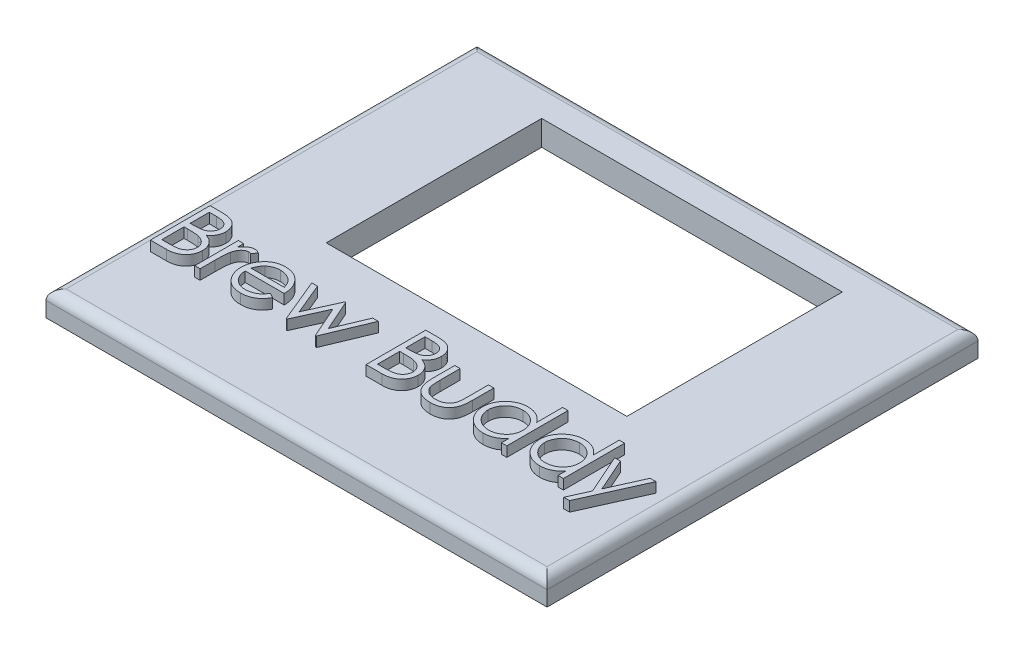
from build123d import *

# Parameters (mm, degrees)
SKETCH1_W           = 100
SKETCH1_H           = 86
BOSS_EXTRUDE1_DEPTH = 5
SKETCH2_W           = 60
SKETCH2_H           = 43
CUT_EXTRUDE1_DEPTH  = 5
BOSS_EXTRUDE2_DEPTH = 2
FILLET1_R           = 2
SKETCH5_R           = 2.65
CUT_EXTRUDE2_DEPTH  = 3


with BuildPart() as part:
    # Sketch1 → Boss-Extrude1 (new body)
    with BuildSketch(Plane(origin=(0, 0, 0), x_dir=(1, 0, 0), z_dir=(0, 1, 0))):
        Rectangle(SKETCH1_W, SKETCH1_H)
    extrude(amount=BOSS_EXTRUDE1_DEPTH)

    # Sketch2 → Cut-Extrude1 (cut)
    with BuildSketch(Plane(origin=(0, 5, 0), x_dir=(1, 0, 0), z_dir=(0, 1, 0))):
        with Locations((0, 14.426515267)):
            Rectangle(SKETCH2_W, SKETCH2_H)
    extrude(amount=-CUT_EXTRUDE1_DEPTH, mode=Mode.SUBTRACT)

    # Sketch4 → Boss-Extrude2 (add)
    with BuildSketch(Plane(origin=(0, 5, 0), x_dir=(1, 0, 0), z_dir=(0, 1, 0))):
        with BuildLine():
            Line((-46.0249044, -14.23647048), (-43.701850013, -14.23647048))
            add(Edge.make_bspline(
                [(-43.701850013, -14.23647048), (-43.588133493, -14.237068345), (-43.367722577, -14.238227156), (-43.047208225, -14.256199236), (-42.747004682, -14.280704578), (-42.467024885, -14.319587304), (-42.20739821, -14.366503974), (-41.96734223, -14.423319973), (-41.747620304, -14.491446222), (-41.485299299, -14.599780446), (-41.186212051, -14.760763724), (-40.862367519, -14.998645718), (-40.58544774, -15.289608829), (-40.346688929, -15.617822148), (-40.156865477, -15.9788733), (-40.019537778, -16.364156791), (-39.932595363, -16.768703073), (-39.923653993, -17.04643567), (-39.919135169, -17.186797252)],
                knots=[0, 0, 0, 0, 1.001505555, 1.941167018, 2.826882275, 3.653841531, 4.429895133, 5.150066043, 5.825578002, 6.45369114, 7.647487171, 8.808567382, 9.977351308, 11.170798116, 12.373658725, 13.556498008, 14.765093433, 16, 16, 16, 16], degree=3))
            add(Edge.make_bspline(
                [(-39.919135169, -17.186797252), (-39.922854064, -17.318284964), (-39.930162043, -17.576670718), (-40.000044108, -17.954589071), (-40.10944781, -18.314332057), (-40.261525488, -18.654586779), (-40.459176029, -18.967665409), (-40.693417274, -19.25609352), (-40.976026754, -19.507659169), (-41.187764918, -19.648298864), (-41.295318312, -19.719737457)],
                knots=[0, 0, 0, 0, 1.044552857, 2.05264487, 3.044412934, 4.028983338, 5.005914585, 5.980388656, 6.974128949, 8, 8, 8, 8], degree=3))
            add(Edge.make_bspline(
                [(-41.295318312, -19.719737457), (-41.160061857, -19.771665712), (-40.901282754, -19.871017328), (-40.545163372, -20.046670112), (-40.238339837, -20.237721577), (-39.978453117, -20.446359388), (-39.756188416, -20.671247396), (-39.562106535, -20.915683098), (-39.396502932, -21.182855122), (-39.254604504, -21.469977863), (-39.143880611, -21.77411951), (-39.060959008, -22.092427239), (-39.013444739, -22.423759655), (-39.006683209, -22.649248311), (-39.003269784, -22.763081808)],
                knots=[0, 0, 0, 0, 1.27268992, 2.434971085, 3.483601985, 4.442670788, 5.356604649, 6.2567628, 7.179492994, 8.113709626, 9.066344395, 10.018646069, 10.999752585, 12, 12, 12, 12], degree=3))
            add(Edge.make_bspline(
                [(-39.003269784, -22.763081808), (-39.006592805, -22.879310185), (-39.013130942, -23.107992774), (-39.061368167, -23.44393658), (-39.143042004, -23.764979925), (-39.255542958, -24.073199341), (-39.402371903, -24.367998549), (-39.581060781, -24.649711527), (-39.79411994, -24.915507777), (-40.032458806, -25.168340816), (-40.302091641, -25.395674628), (-40.592997914, -25.598134309), (-40.908841199, -25.764638324), (-41.244434143, -25.904506219), (-41.603541325, -26.011346778), (-41.984550195, -26.086092766), (-42.38713215, -26.136456329), (-42.663390321, -26.140596999), (-42.805065157, -26.14272048)],
                knots=[0, 0, 0, 0, 0.978564426, 1.925352924, 2.850884081, 3.763762016, 4.682927383, 5.618979971, 6.567305752, 7.547517671, 8.540179244, 9.531824382, 10.526200242, 11.540722885, 12.589160233, 13.674978461, 14.80764778, 16, 16, 16, 16], degree=3))
            Line((-42.805065157, -26.14272048), (-46.0249044, -26.14272048))
            Line((-46.0249044, -26.14272048), (-46.0249044, -14.23647048))
        make_face()
        with BuildLine():
            Line((-44.956394784, -15.457624326), (-44.956394784, -19.273730095))
            Line((-44.956394784, -19.273730095), (-44.238489886, -19.273730095))
            add(Edge.make_bspline(
                [(-44.238489886, -19.273730095), (-44.133548895, -19.272369643), (-43.930781514, -19.269740971), (-43.637139723, -19.262211061), (-43.364571581, -19.241126645), (-43.113547577, -19.220048289), (-42.884463013, -19.185776701), (-42.677825413, -19.144982069), (-42.490391793, -19.101837543), (-42.274243875, -19.028462771), (-42.029067148, -18.920021751), (-41.767697392, -18.751729165), (-41.537279241, -18.551281142), (-41.342706665, -18.31999046), (-41.183464073, -18.065311738), (-41.072859382, -17.791308511), (-40.997859245, -17.504809669), (-40.991084482, -17.308124363), (-40.987644784, -17.208262847)],
                knots=[0, 0, 0, 0, 1.156816544, 2.235205308, 3.236616184, 4.169592532, 5.011045266, 5.787822928, 6.49130361, 7.128639758, 8.301311294, 9.436451833, 10.541879658, 11.654887649, 12.756523258, 13.837046038, 14.901820046, 16, 16, 16, 16], degree=3))
            add(Edge.make_bspline(
                [(-40.987644784, -17.208262847), (-40.989434736, -17.142180535), (-40.992945923, -17.012552864), (-41.021702247, -16.823585865), (-41.070577657, -16.645863814), (-41.133355208, -16.476951171), (-41.221082801, -16.322129609), (-41.324372796, -16.176046059), (-41.449169653, -16.04367537), (-41.591219083, -15.91995413), (-41.754534131, -15.810265156), (-41.939017364, -15.714196132), (-42.14716473, -15.636836882), (-42.375468281, -15.569086399), (-42.627442249, -15.521501221), (-42.900178899, -15.481858894), (-43.195912184, -15.461676977), (-43.400512935, -15.459005341), (-43.506274592, -15.457624326)],
                knots=[0, 0, 0, 0, 0.91205012, 1.789085906, 2.630437955, 3.453916878, 4.269457761, 5.079663411, 5.91843418, 6.774407191, 7.675494373, 8.627863946, 9.638891023, 10.736472738, 11.911756761, 13.175263542, 14.539845004, 16, 16, 16, 16], degree=3))
            Line((-43.506274592, -15.457624326), (-44.956394784, -15.457624326))
        make_face(mode=Mode.SUBTRACT)
        with BuildLine():
            Line((-44.956394784, -20.494883941), (-44.956394784, -24.921566633))
            Line((-44.956394784, -24.921566633), (-43.434722609, -24.921566633))
            add(Edge.make_bspline(
                [(-43.434722609, -24.921566633), (-43.325801084, -24.920261207), (-43.115869204, -24.91774517), (-42.812765913, -24.909531372), (-42.53183589, -24.890847827), (-42.274361071, -24.8614365), (-42.037561228, -24.829533025), (-41.824277077, -24.78663215), (-41.632779696, -24.737479882), (-41.410730488, -24.661503814), (-41.160687304, -24.543473855), (-40.891228944, -24.365512067), (-40.651654041, -24.153501529), (-40.448209365, -23.908127616), (-40.281477681, -23.641321048), (-40.160185463, -23.358478385), (-40.085377281, -23.064273153), (-40.076321151, -22.863681032), (-40.0717794, -22.763081808)],
                knots=[0, 0, 0, 0, 1.160039823, 2.235823828, 3.228722157, 4.157150951, 4.99529583, 5.772374946, 6.472645482, 7.099169577, 8.269452708, 9.405989375, 10.527446681, 11.663510218, 12.788923519, 13.866172445, 14.929861265, 16, 16, 16, 16], degree=3))
            add(Edge.make_bspline(
                [(-40.0717794, -22.763081808), (-40.072718647, -22.700171426), (-40.074581993, -22.575365413), (-40.102682835, -22.39195535), (-40.143551445, -22.21429412), (-40.196386055, -22.041899306), (-40.273332635, -21.877887731), (-40.363162043, -21.719015631), (-40.468486097, -21.565072992), (-40.632602411, -21.370449165), (-40.871312465, -21.146213612), (-41.21049355, -20.926670859), (-41.596161813, -20.749615372), (-41.875882124, -20.67443769), (-42.020378408, -20.635602841)],
                knots=[0, 0, 0, 0, 0.723448775, 1.435228256, 2.130040452, 2.821711965, 3.505591119, 4.210454504, 4.921174351, 5.648778258, 7.137944449, 8.670945889, 10.280296675, 12, 12, 12, 12], degree=3))
            add(Edge.make_bspline(
                [(-42.020378408, -20.635602841), (-42.078307743, -20.623849386), (-42.20391049, -20.598365471), (-42.408723777, -20.571465158), (-42.642548474, -20.547499374), (-42.905924512, -20.529772133), (-43.199185114, -20.511448266), (-43.522956596, -20.504322133), (-43.875916747, -20.495820186), (-44.120819371, -20.495204006), (-44.248030151, -20.494883941)],
                knots=[0, 0, 0, 0, 0.634451884, 1.375622551, 2.216452059, 3.157844607, 4.20941857, 5.370758133, 6.634282058, 8, 8, 8, 8], degree=3))
            Line((-44.248030151, -20.494883941), (-44.956394784, -20.494883941))
        make_face(mode=Mode.SUBTRACT)
        with BuildLine():
            Line((-37.171539015, -17.441999326), (-36.1030294, -17.441999326))
            Line((-36.1030294, -17.441999326), (-36.1030294, -18.722779824))
            add(Edge.make_bspline(
                [(-36.1030294, -18.722779824), (-36.024146211, -18.603527408), (-35.873282727, -18.375458089), (-35.622527137, -18.073824128), (-35.365680983, -17.824081871), (-35.101514676, -17.625065437), (-34.828085604, -17.476022595), (-34.551394724, -17.366848967), (-34.267088884, -17.302292207), (-34.076038053, -17.293673242), (-33.980320565, -17.289355095)],
                knots=[0, 0, 0, 0, 1.2804753, 2.448899062, 3.506932113, 4.484331642, 5.4025378, 6.288909075, 7.142734305, 8, 8, 8, 8], degree=3))
            add(Edge.make_bspline(
                [(-33.980320565, -17.289355095), (-33.90607208, -17.293405011), (-33.753300995, -17.301737977), (-33.522038792, -17.360285515), (-33.283765978, -17.453759859), (-33.13020125, -17.54166276), (-33.050144784, -17.587488358)],
                knots=[0, 0, 0, 0, 0.901110191, 1.854092781, 2.881294221, 4, 4, 4, 4], degree=3))
            Line((-33.050144784, -17.587488358), (-33.636871046, -18.512894007))
            add(Edge.make_bspline(
                [(-33.636871046, -18.512894007), (-33.688268698, -18.489965066), (-33.785831282, -18.446441547), (-33.928551726, -18.394931673), (-34.060137345, -18.364601638), (-34.143969449, -18.360006787), (-34.183051184, -18.35786471)],
                knots=[0, 0, 0, 0, 1.180555205, 2.24091978, 3.179933427, 4, 4, 4, 4], degree=3))
            add(Edge.make_bspline(
                [(-34.183051184, -18.35786471), (-34.268795689, -18.363579837), (-34.443689622, -18.37523704), (-34.700471714, -18.466877092), (-34.949643011, -18.614940632), (-35.147530541, -18.77914861), (-35.300754634, -18.937494243), (-35.410088794, -19.075771398), (-35.510382781, -19.230820135), (-35.606211834, -19.399989863), (-35.693523067, -19.586169072), (-35.775011719, -19.787497682), (-35.848690529, -20.004208879), (-35.890703414, -20.155188702), (-35.912224111, -20.232526669)],
                knots=[0, 0, 0, 0, 1.125678352, 2.296057538, 3.5422874, 4.923748041, 5.663163013, 6.437101912, 7.23742474, 8.08941207, 8.991984279, 9.93940061, 10.944477711, 12, 12, 12, 12], degree=3))
            add(Edge.make_bspline(
                [(-35.912224111, -20.232526669), (-35.928322699, -20.301505269), (-35.963979849, -20.454287625), (-35.998649276, -20.71060716), (-36.032903619, -21.013446571), (-36.057044794, -21.36364882), (-36.079421884, -21.760339365), (-36.092042788, -22.204122538), (-36.102599007, -22.695453848), (-36.102881583, -23.03894696), (-36.1030294, -23.218629434)],
                knots=[0, 0, 0, 0, 0.566838948, 1.255505196, 2.06880316, 3.007127437, 4.065329342, 5.249902469, 6.561414163, 8, 8, 8, 8], degree=3))
            Line((-36.1030294, -23.218629434), (-36.1030294, -26.14272048))
            Line((-36.1030294, -26.14272048), (-37.171539015, -26.14272048))
            Line((-37.171539015, -26.14272048), (-37.171539015, -17.441999326))
        make_face()
        with BuildLine():
            Line((-24.840747248, -23.395124326), (-23.891490938, -23.893603142))
            add(Edge.make_bspline(
                [(-23.891490938, -23.893603142), (-23.96713507, -24.027780903), (-24.114308595, -24.28883769), (-24.367403997, -24.647494287), (-24.632716315, -24.970145891), (-24.922221778, -25.248172662), (-25.22725881, -25.490554605), (-25.549519002, -25.702614527), (-25.89068007, -25.883312351), (-26.250758151, -26.035550861), (-26.63277716, -26.152604586), (-27.037662854, -26.235282338), (-27.466190888, -26.286388278), (-27.759922089, -26.292324873), (-27.910327326, -26.29536471)],
                knots=[0, 0, 0, 0, 1.120438281, 2.179929193, 3.190490725, 4.156257408, 5.095198341, 6.022838206, 6.959905092, 7.901321166, 8.864066838, 9.862729781, 10.905609505, 12, 12, 12, 12], degree=3))
            add(Edge.make_bspline(
                [(-27.910327326, -26.29536471), (-28.077497803, -26.291462266), (-28.403598975, -26.283849727), (-28.878283293, -26.218220897), (-29.325207922, -26.111158677), (-29.744347734, -25.961597326), (-30.13467629, -25.766241875), (-30.496969376, -25.528254709), (-30.833132227, -25.248858378), (-31.132571725, -24.925632798), (-31.402142433, -24.579732569), (-31.640015088, -24.219293354), (-31.838874742, -23.845222028), (-32.000638532, -23.459899978), (-32.131283653, -23.06575584), (-32.222338244, -22.659203437), (-32.27482694, -22.241343101), (-32.282870277, -21.958663772), (-32.28692363, -21.816210564)],
                knots=[0, 0, 0, 0, 1.145258523, 2.234067595, 3.276747158, 4.290159414, 5.277019952, 6.260822364, 7.254936242, 8.264827045, 9.274100331, 10.257902744, 11.220704747, 12.172965371, 13.118907548, 14.062713208, 15.023725156, 16, 16, 16, 16], degree=3))
            add(Edge.make_bspline(
                [(-32.28692363, -21.816210564), (-32.283320658, -21.682537971), (-32.276180044, -21.417616545), (-32.231171741, -21.025507862), (-32.151405672, -20.644411072), (-32.041948713, -20.274009513), (-31.900600277, -19.914923361), (-31.72767996, -19.566934073), (-31.522918389, -19.230411945), (-31.364828312, -19.018129856), (-31.285195866, -18.911200047)],
                knots=[0, 0, 0, 0, 1.024358464, 2.0301432, 3.019427413, 4.004406732, 4.986367066, 5.972626655, 6.978780325, 8, 8, 8, 8], degree=3))
            add(Edge.make_bspline(
                [(-31.285195866, -18.911200047), (-31.177333124, -18.782378266), (-30.965024457, -18.52881545), (-30.605944355, -18.195650253), (-30.21711958, -17.91655491), (-29.803422888, -17.685209206), (-29.360046132, -17.509426532), (-28.892949348, -17.378431989), (-28.396813916, -17.305028219), (-28.05763812, -17.294660142), (-27.884091599, -17.289355095)],
                knots=[0, 0, 0, 0, 1.030682036, 2.02871468, 2.997146059, 3.962720338, 4.930598197, 5.918074684, 6.934738563, 8, 8, 8, 8], degree=3))
            add(Edge.make_bspline(
                [(-27.884091599, -17.289355095), (-27.705676085, -17.293961279), (-27.355665516, -17.302997562), (-26.84528839, -17.386771072), (-26.362368452, -17.519619494), (-25.907098951, -17.70724087), (-25.479433728, -17.949310417), (-25.082152613, -18.249150074), (-24.708461307, -18.59755446), (-24.491058017, -18.865490021), (-24.38042949, -19.001832559)],
                knots=[0, 0, 0, 0, 1.056321875, 2.072262726, 3.055038591, 4.01806755, 4.982017516, 5.957941055, 6.960871419, 8, 8, 8, 8], degree=3))
            add(Edge.make_bspline(
                [(-24.38042949, -19.001832559), (-24.305158387, -19.104578671), (-24.155117209, -19.309386985), (-23.967178413, -19.643344225), (-23.804037632, -19.992743657), (-23.673637113, -20.36323315), (-23.568047381, -20.750422972), (-23.491654096, -21.157081093), (-23.446853875, -21.583086416), (-23.438047682, -21.873349074), (-23.433558246, -22.021326249)],
                knots=[0, 0, 0, 0, 0.94817472, 1.890038105, 2.849395472, 3.817997239, 4.812318967, 5.836947057, 6.897266129, 8, 8, 8, 8], degree=3))
            Line((-23.433558246, -22.021326249), (-31.218414015, -22.021326249))
            add(Edge.make_bspline(
                [(-31.218414015, -22.021326249), (-31.213176604, -22.135968007), (-31.202877446, -22.3614064), (-31.154860754, -22.691280224), (-31.079175193, -23.00551454), (-30.972804542, -23.301752388), (-30.843989649, -23.583862911), (-30.68619538, -23.849753412), (-30.497942076, -24.098212799), (-30.287964474, -24.331463508), (-30.054237658, -24.539179133), (-29.808347242, -24.725092765), (-29.546771811, -24.880913589), (-29.271573866, -25.007391607), (-28.983198418, -25.106405057), (-28.681554612, -25.173991126), (-28.367236019, -25.219259052), (-28.152972049, -25.224292556), (-28.043891028, -25.226855095)],
                knots=[0, 0, 0, 0, 1.094153842, 2.151609401, 3.174256925, 4.172055639, 5.149267565, 6.128595816, 7.11444997, 8.118368179, 9.117203808, 10.09244225, 11.054858984, 12.015122123, 12.976791628, 13.957293641, 14.960065497, 16, 16, 16, 16], degree=3))
            add(Edge.make_bspline(
                [(-28.043891028, -25.226855095), (-27.937241142, -25.224786616), (-27.72562731, -25.220682358), (-27.410482964, -25.180772911), (-27.100445822, -25.116240099), (-26.796799084, -25.0281679), (-26.505705403, -24.920750216), (-26.236129023, -24.791132459), (-25.988206147, -24.647748053), (-25.756486823, -24.483749069), (-25.531727462, -24.283015861), (-25.308765968, -24.032522918), (-25.069699852, -23.73626981), (-24.920056684, -23.5132975), (-24.840747248, -23.395124326)],
                knots=[0, 0, 0, 0, 0.99110716, 1.966546729, 2.947904876, 3.932708344, 4.903319531, 5.828989031, 6.710028674, 7.56322171, 8.463672341, 9.504779593, 10.677557249, 12, 12, 12, 12], degree=3))
        make_face()
        with BuildLine():
            add(Edge.make_bspline(
                [(-24.502067861, -20.952816633), (-24.541176914, -20.811088465), (-24.616449252, -20.538307363), (-24.773735456, -20.160570048), (-24.95087168, -19.824854956), (-25.160495605, -19.533731383), (-25.398003949, -19.275183718), (-25.672341579, -19.049241924), (-25.979985109, -18.847116488), (-26.319344329, -18.676508431), (-26.678715044, -18.53128668), (-27.054973608, -18.43391017), (-27.438891619, -18.367202709), (-27.698564503, -18.36099068), (-27.829235079, -18.35786471)],
                knots=[0, 0, 0, 0, 1.154881502, 2.222775134, 3.210006277, 4.132804581, 5.035138423, 5.962687519, 6.919655026, 7.923214229, 8.944639381, 9.960483929, 10.97369054, 12, 12, 12, 12], degree=3))
            add(Edge.make_bspline(
                [(-27.829235079, -18.35786471), (-27.935879151, -18.359945486), (-28.14669206, -18.364058742), (-28.45727873, -18.403077664), (-28.755546277, -18.467574993), (-29.043695514, -18.555902212), (-29.317950433, -18.673633261), (-29.583952278, -18.811688702), (-29.834937376, -18.980218554), (-29.991900176, -19.108666087), (-30.071197218, -19.173557318)],
                knots=[0, 0, 0, 0, 1.04873581, 2.073130211, 3.073294108, 4.04793562, 5.032784715, 6.005352987, 6.992311501, 8, 8, 8, 8], degree=3))
            add(Edge.make_bspline(
                [(-30.071197218, -19.173557318), (-30.127984186, -19.224904946), (-30.24290717, -19.328820029), (-30.396465551, -19.507853312), (-30.543492337, -19.700909965), (-30.677296995, -19.91537597), (-30.800025213, -20.148809155), (-30.914869422, -20.399240575), (-31.018237484, -20.668570599), (-31.076394787, -20.856255414), (-31.106315908, -20.952816633)],
                knots=[0, 0, 0, 0, 0.879870761, 1.780643979, 2.707998968, 3.669668524, 4.684282772, 5.740141944, 6.837334558, 8, 8, 8, 8], degree=3))
            Line((-31.106315908, -20.952816633), (-24.502067861, -20.952816633))
        make_face(mode=Mode.SUBTRACT)
        Polygon((-22.517692861, -17.441999326), (-21.37286113, -17.441999326), (-18.777909207, -23.700412787), (-15.942065607, -17.441999326), (-15.758415517, -17.441999326), (-12.977428438, -23.700412787), (-10.36101092, -17.441999326), (-9.237644784, -17.441999326), (-12.874870595, -26.14272048), (-13.094296677, -26.14272048), (-15.877668823, -19.884307018), (-18.713512422, -26.14272048), (-18.909087843, -26.14272048), align=None)
        with BuildLine():
            Line((-2.979231323, -14.23647048), (-0.656176936, -14.23647048))
            add(Edge.make_bspline(
                [(-0.656176936, -14.23647048), (-0.542460416, -14.237068345), (-0.3220495, -14.238227156), (-0.001535148, -14.256199236), (0.298668395, -14.280704578), (0.578648192, -14.319587304), (0.838274867, -14.366503974), (1.078330847, -14.423319973), (1.298052773, -14.491446222), (1.560373778, -14.599780446), (1.859461026, -14.760763724), (2.183305558, -14.998645718), (2.460225337, -15.289608829), (2.698984148, -15.617822148), (2.8888076, -15.9788733), (3.026135298, -16.364156791), (3.113077714, -16.768703073), (3.122019084, -17.04643567), (3.126537908, -17.186797252)],
                knots=[0, 0, 0, 0, 1.001505555, 1.941167018, 2.826882275, 3.653841531, 4.429895133, 5.150066043, 5.825578002, 6.45369114, 7.647487171, 8.808567382, 9.977351308, 11.170798116, 12.373658725, 13.556498008, 14.765093433, 16, 16, 16, 16], degree=3))
            add(Edge.make_bspline(
                [(3.126537908, -17.186797252), (3.122819013, -17.318284964), (3.115511034, -17.576670718), (3.045628969, -17.954589071), (2.936225266, -18.314332057), (2.784147588, -18.654586779), (2.586497048, -18.967665409), (2.352255803, -19.25609352), (2.069646323, -19.507659169), (1.857908159, -19.648298864), (1.750354765, -19.719737457)],
                knots=[0, 0, 0, 0, 1.044552857, 2.05264487, 3.044412934, 4.028983338, 5.005914585, 5.980388656, 6.974128949, 8, 8, 8, 8], degree=3))
            add(Edge.make_bspline(
                [(1.750354765, -19.719737457), (1.88561122, -19.771665712), (2.144390323, -19.871017328), (2.500509704, -20.046670112), (2.80733324, -20.237721577), (3.067219959, -20.446359388), (3.289484661, -20.671247396), (3.483566542, -20.915683098), (3.649170145, -21.182855122), (3.791068573, -21.469977863), (3.901792466, -21.77411951), (3.984714069, -22.092427239), (4.032228338, -22.423759655), (4.038989868, -22.649248311), (4.042403293, -22.763081808)],
                knots=[0, 0, 0, 0, 1.27268992, 2.434971085, 3.483601985, 4.442670788, 5.356604649, 6.2567628, 7.179492994, 8.113709626, 9.066344395, 10.018646069, 10.999752585, 12, 12, 12, 12], degree=3))
            add(Edge.make_bspline(
                [(4.042403293, -22.763081808), (4.039080272, -22.879310185), (4.032542135, -23.107992774), (3.98430491, -23.44393658), (3.902631073, -23.764979925), (3.790130119, -24.073199341), (3.643301174, -24.367998549), (3.464612296, -24.649711527), (3.251553137, -24.915507777), (3.01321427, -25.168340816), (2.743581436, -25.395674628), (2.452675163, -25.598134309), (2.136831878, -25.764638324), (1.801238934, -25.904506219), (1.442131752, -26.011346778), (1.061122882, -26.086092766), (0.658540927, -26.136456329), (0.382282756, -26.140596999), (0.24060792, -26.14272048)],
                knots=[0, 0, 0, 0, 0.978564426, 1.925352924, 2.850884081, 3.763762016, 4.682927383, 5.618979971, 6.567305752, 7.547517671, 8.540179244, 9.531824382, 10.526200242, 11.540722885, 12.589160233, 13.674978461, 14.80764778, 16, 16, 16, 16], degree=3))
            Line((0.24060792, -26.14272048), (-2.979231323, -26.14272048))
            Line((-2.979231323, -26.14272048), (-2.979231323, -14.23647048))
        make_face()
        with BuildLine():
            Line((-1.910721707, -15.457624326), (-1.910721707, -19.273730095))
            Line((-1.910721707, -19.273730095), (-1.192816809, -19.273730095))
            add(Edge.make_bspline(
                [(-1.192816809, -19.273730095), (-1.087875818, -19.272369643), (-0.885108437, -19.269740971), (-0.591466646, -19.262211061), (-0.318898504, -19.241126645), (-0.0678745, -19.220048289), (0.161210064, -19.185776701), (0.367847664, -19.144982069), (0.555281284, -19.101837543), (0.771429202, -19.028462771), (1.016605929, -18.920021751), (1.277975685, -18.751729165), (1.508393836, -18.551281142), (1.702966412, -18.31999046), (1.862209004, -18.065311738), (1.972813695, -17.791308511), (2.047813832, -17.504809669), (2.054588595, -17.308124363), (2.058028293, -17.208262847)],
                knots=[0, 0, 0, 0, 1.156816544, 2.235205308, 3.236616184, 4.169592532, 5.011045266, 5.787822928, 6.49130361, 7.128639758, 8.301311294, 9.436451833, 10.541879658, 11.654887649, 12.756523258, 13.837046038, 14.901820046, 16, 16, 16, 16], degree=3))
            add(Edge.make_bspline(
                [(2.058028293, -17.208262847), (2.056238341, -17.142180535), (2.052727154, -17.012552864), (2.02397083, -16.823585865), (1.97509542, -16.645863814), (1.912317869, -16.476951171), (1.824590276, -16.322129609), (1.721300281, -16.176046059), (1.596503423, -16.04367537), (1.454453994, -15.91995413), (1.291138946, -15.810265156), (1.106655713, -15.714196132), (0.898508347, -15.636836882), (0.670204796, -15.569086399), (0.418230828, -15.521501221), (0.145494178, -15.481858894), (-0.150239107, -15.461676977), (-0.354839858, -15.459005341), (-0.460601515, -15.457624326)],
                knots=[0, 0, 0, 0, 0.91205012, 1.789085906, 2.630437955, 3.453916878, 4.269457761, 5.079663411, 5.91843418, 6.774407191, 7.675494373, 8.627863946, 9.638891023, 10.736472738, 11.911756761, 13.175263542, 14.539845004, 16, 16, 16, 16], degree=3))
            Line((-0.460601515, -15.457624326), (-1.910721707, -15.457624326))
        make_face(mode=Mode.SUBTRACT)
        with BuildLine():
            Line((-1.910721707, -20.494883941), (-1.910721707, -24.921566633))
            Line((-1.910721707, -24.921566633), (-0.389049532, -24.921566633))
            add(Edge.make_bspline(
                [(-0.389049532, -24.921566633), (-0.280128007, -24.920261207), (-0.070196127, -24.91774517), (0.232907164, -24.909531372), (0.513837187, -24.890847827), (0.771312006, -24.8614365), (1.008111849, -24.829533025), (1.221396, -24.78663215), (1.412893381, -24.737479882), (1.634942589, -24.661503814), (1.884985773, -24.543473855), (2.154444133, -24.365512067), (2.394019036, -24.153501529), (2.597463712, -23.908127616), (2.764195396, -23.641321048), (2.885487614, -23.358478385), (2.960295796, -23.064273153), (2.969351926, -22.863681032), (2.973893677, -22.763081808)],
                knots=[0, 0, 0, 0, 1.160039823, 2.235823828, 3.228722157, 4.157150951, 4.99529583, 5.772374946, 6.472645482, 7.099169577, 8.269452708, 9.405989375, 10.527446681, 11.663510218, 12.788923519, 13.866172445, 14.929861265, 16, 16, 16, 16], degree=3))
            add(Edge.make_bspline(
                [(2.973893677, -22.763081808), (2.97295443, -22.700171426), (2.971091084, -22.575365413), (2.942990242, -22.39195535), (2.902121632, -22.21429412), (2.849287022, -22.041899306), (2.772340442, -21.877887731), (2.682511034, -21.719015631), (2.57718698, -21.565072992), (2.413070666, -21.370449165), (2.174360612, -21.146213612), (1.835179527, -20.926670859), (1.449511264, -20.749615372), (1.169790953, -20.67443769), (1.025294669, -20.635602841)],
                knots=[0, 0, 0, 0, 0.723448775, 1.435228256, 2.130040452, 2.821711965, 3.505591119, 4.210454504, 4.921174351, 5.648778258, 7.137944449, 8.670945889, 10.280296675, 12, 12, 12, 12], degree=3))
            add(Edge.make_bspline(
                [(1.025294669, -20.635602841), (0.967365334, -20.623849386), (0.841762587, -20.598365471), (0.6369493, -20.571465158), (0.403124603, -20.547499374), (0.139748565, -20.529772133), (-0.153512037, -20.511448266), (-0.477283519, -20.504322133), (-0.83024367, -20.495820186), (-1.075146294, -20.495204006), (-1.202357074, -20.494883941)],
                knots=[0, 0, 0, 0, 0.634451884, 1.375622551, 2.216452059, 3.157844607, 4.20941857, 5.370758133, 6.634282058, 8, 8, 8, 8], degree=3))
            Line((-1.202357074, -20.494883941), (-1.910721707, -20.494883941))
        make_face(mode=Mode.SUBTRACT)
        with BuildLine():
            Line((6.026778293, -17.441999326), (7.095287908, -17.441999326))
            Line((7.095287908, -17.441999326), (7.095287908, -21.477531177))
            add(Edge.make_bspline(
                [(7.095287908, -21.477531177), (7.095770638, -21.595990707), (7.096694078, -21.822598241), (7.102956565, -22.148677046), (7.117686615, -22.44604997), (7.136103286, -22.714888798), (7.159786982, -22.955148049), (7.187965199, -23.165988541), (7.219460365, -23.349801256), (7.250289776, -23.460506779), (7.264627602, -23.511992565)],
                knots=[0, 0, 0, 0, 1.388932606, 2.656963016, 3.823490214, 4.879454478, 5.816252168, 6.653371382, 7.373723809, 8, 8, 8, 8], degree=3))
            add(Edge.make_bspline(
                [(7.264627602, -23.511992565), (7.287628623, -23.576704296), (7.333152479, -23.704782416), (7.41572567, -23.889802157), (7.517875636, -24.061168073), (7.629657729, -24.225488177), (7.758583392, -24.377894936), (7.903021415, -24.518130979), (8.058136846, -24.651494897), (8.288624916, -24.80928602), (8.603831884, -24.97840692), (9.017668489, -25.124329302), (9.4663784, -25.211536868), (9.77650124, -25.221654646), (9.93590164, -25.226855095)],
                knots=[0, 0, 0, 0, 0.725840625, 1.436591201, 2.137033971, 2.831655856, 3.53531722, 4.242432219, 4.957935707, 5.694543706, 7.190802206, 8.724350549, 10.316345118, 12, 12, 12, 12], degree=3))
            add(Edge.make_bspline(
                [(9.93590164, -25.226855095), (10.095287233, -25.221544062), (10.403668866, -25.211268195), (10.847448717, -25.126959908), (11.253116475, -24.986106626), (11.616600514, -24.789458199), (11.936252167, -24.54880886), (12.20262702, -24.26643068), (12.422407056, -23.95125732), (12.51836946, -23.716111335), (12.566629555, -23.597854945)],
                knots=[0, 0, 0, 0, 1.157059328, 2.238695713, 3.266970494, 4.264342957, 5.228770407, 6.160125903, 7.074715775, 8, 8, 8, 8], degree=3))
            add(Edge.make_bspline(
                [(12.566629555, -23.597854945), (12.580897427, -23.550344589), (12.612440207, -23.445310797), (12.646329992, -23.267126117), (12.676859187, -23.054634918), (12.70292767, -22.806446726), (12.721518983, -22.523210127), (12.731540734, -22.205013636), (12.742862813, -21.852856152), (12.743034658, -21.606336363), (12.743124447, -21.477531177)],
                knots=[0, 0, 0, 0, 0.557542046, 1.232589297, 2.036731608, 2.971723315, 4.038036528, 5.22795436, 6.551621927, 8, 8, 8, 8], degree=3))
            Line((12.743124447, -21.477531177), (12.743124447, -17.441999326))
            Line((12.743124447, -17.441999326), (13.811634062, -17.441999326))
            Line((13.811634062, -17.441999326), (13.811634062, -21.67787673))
            add(Edge.make_bspline(
                [(13.811634062, -21.67787673), (13.810131511, -21.821796661), (13.807216356, -22.101021015), (13.788481554, -22.506800001), (13.756335996, -22.884950138), (13.707545256, -23.235671591), (13.650171845, -23.558696596), (13.576161666, -23.854439158), (13.487789268, -24.121988087), (13.388098186, -24.366038239), (13.270322011, -24.587313834), (13.145044379, -24.797325853), (13.000384218, -24.990863427), (12.848085474, -25.177560698), (12.678670913, -25.348131429), (12.495315143, -25.506489575), (12.300598902, -25.65505587), (12.090201184, -25.788036026), (11.867193506, -25.907835507), (11.631300563, -26.014025916), (11.379633061, -26.09805879), (11.11543801, -26.170553108), (10.837421019, -26.22741215), (10.545850111, -26.267507525), (10.240823497, -26.292086552), (10.03294221, -26.294253642), (9.926361376, -26.29536471)],
                knots=[0, 0, 0, 0, 1.493040784, 2.896703357, 4.213163133, 5.428574705, 6.569057535, 7.615249723, 8.588095153, 9.490268104, 10.346124644, 11.18633936, 12.024365274, 12.850166724, 13.684164916, 14.514361689, 15.362232829, 16.222528818, 17.093394965, 17.986930858, 18.902426812, 19.842810585, 20.827885679, 21.843828298, 22.894529745, 24, 24, 24, 24], degree=3))
            add(Edge.make_bspline(
                [(9.926361376, -26.29536471), (9.820577698, -26.294209099), (9.612702924, -26.291938216), (9.307660567, -26.267643317), (9.015281826, -26.227474451), (8.736606184, -26.170136613), (8.471353993, -26.098566205), (8.21845082, -26.013509536), (7.980857985, -25.907780397), (7.75572099, -25.788794242), (7.544802151, -25.654201653), (7.34712922, -25.506672875), (7.162967249, -25.346428143), (6.992275616, -25.174136687), (6.837450222, -24.987661216), (6.696561723, -24.788501765), (6.567441146, -24.578631696), (6.450580314, -24.353898974), (6.350187646, -24.107024548), (6.261553283, -23.83387103), (6.189059057, -23.531443718), (6.130063696, -23.200001176), (6.082603885, -22.84112965), (6.049653705, -22.452753166), (6.031230209, -22.035817749), (6.028294259, -21.747856962), (6.026778293, -21.599169548)],
                knots=[0, 0, 0, 0, 1.083640291, 2.129454052, 3.13281866, 4.105697902, 5.042300162, 5.946461698, 6.836384745, 7.703652036, 8.553297018, 9.397182691, 10.228592656, 11.052265423, 11.879314572, 12.708807002, 13.549817954, 14.402308542, 15.300838682, 16.27712199, 17.341985831, 18.484375296, 19.725102775, 21.0496083, 22.476576903, 24, 24, 24, 24], degree=3))
            Line((6.026778293, -21.599169548), (6.026778293, -17.441999326))
        make_face()
        with BuildLine():
            Line((25.107307139, -13.931182018), (25.107307139, -26.14272048))
            Line((25.107307139, -26.14272048), (24.038797524, -26.14272048))
            Line((24.038797524, -26.14272048), (24.038797524, -24.637743767))
            add(Edge.make_bspline(
                [(24.038797524, -24.637743767), (23.918310388, -24.773949886), (23.683178227, -25.039757839), (23.290472281, -25.387019515), (22.874201961, -25.674056484), (22.436387646, -25.905887893), (21.977424693, -26.080032299), (21.498330503, -26.203810216), (20.998909645, -26.28339103), (20.657872617, -26.291337676), (20.485049026, -26.29536471)],
                knots=[0, 0, 0, 0, 1.074387032, 2.096679803, 3.090159297, 4.057316773, 5.018401886, 5.985159533, 6.978961417, 8, 8, 8, 8], degree=3))
            add(Edge.make_bspline(
                [(20.485049026, -26.29536471), (20.331397326, -26.291192855), (20.02838937, -26.282965771), (19.582656527, -26.219140434), (19.153717714, -26.116642516), (18.741167606, -25.974104669), (18.347675754, -25.785030624), (17.969873103, -25.558671557), (17.609716892, -25.289111233), (17.272696746, -24.980950172), (16.962345031, -24.64623151), (16.689993737, -24.289229248), (16.462914064, -23.911487125), (16.273026111, -23.517787736), (16.12676176, -23.105100375), (16.024797879, -22.674852152), (15.961046896, -22.227551779), (15.952823212, -21.922957508), (15.948653293, -21.768509242)],
                knots=[0, 0, 0, 0, 1.033919861, 2.038935746, 3.024066025, 3.998881131, 4.97069526, 5.957263378, 6.95902576, 7.993208707, 9.027059324, 10.027763471, 11.009749337, 11.988697705, 12.965288445, 13.950418724, 14.960734635, 16, 16, 16, 16], degree=3))
            add(Edge.make_bspline(
                [(15.948653293, -21.768509242), (15.952915633, -21.61725325), (15.961342049, -21.318228314), (16.024115949, -20.878449886), (16.129676791, -20.454865446), (16.277817237, -20.048838701), (16.467779602, -19.659878352), (16.698856398, -19.287709303), (16.971064313, -18.931306263), (17.284887233, -18.599049679), (17.624843907, -18.292138482), (17.9885245, -18.025407712), (18.36688227, -17.795049503), (18.765785904, -17.612531874), (19.179331144, -17.464863402), (19.611199563, -17.36269768), (20.059594308, -17.302495185), (20.364021785, -17.293777211), (20.518439951, -17.289355095)],
                knots=[0, 0, 0, 0, 1.020392517, 2.01726096, 2.990465484, 3.961182959, 4.928053699, 5.906110375, 6.912531644, 7.948652711, 8.985773172, 9.998621852, 10.987621588, 11.969261332, 12.953316658, 13.946091881, 14.958173133, 16, 16, 16, 16], degree=3))
            add(Edge.make_bspline(
                [(20.518439951, -17.289355095), (20.696070342, -17.29468602), (21.044739058, -17.305150033), (21.554661708, -17.392597585), (22.036992776, -17.539428446), (22.494509099, -17.740444323), (22.924483112, -18.001704021), (23.330066595, -18.317224572), (23.704206291, -18.695935667), (23.925566688, -18.980364323), (24.038797524, -19.125855996)],
                knots=[0, 0, 0, 0, 1.031072012, 2.023879775, 2.993683497, 3.952812103, 4.918022106, 5.908088563, 6.929940113, 8, 8, 8, 8], degree=3))
            Line((24.038797524, -19.125855996), (24.038797524, -13.931182018))
            Line((24.038797524, -13.931182018), (25.107307139, -13.931182018))
        make_face()
        with BuildLine():
            add(Edge.make_bspline(
                [(20.532750348, -18.35786471), (20.376559609, -18.363421996), (20.068263935, -18.374391193), (19.615676749, -18.46002603), (19.182583796, -18.602508444), (18.771151168, -18.797369198), (18.387878038, -19.042395525), (18.045339747, -19.338763802), (17.740734665, -19.67838793), (17.484552088, -20.059735288), (17.275714772, -20.468555401), (17.12886978, -20.89590282), (17.0320235, -21.334069753), (17.022129337, -21.631258889), (17.017162908, -21.780434572)],
                knots=[0, 0, 0, 0, 1.031046209, 2.035121221, 3.029706178, 4.034933723, 5.034054252, 6.02443088, 7.017295772, 8.038157696, 9.050218397, 10.03989886, 11.016116709, 12, 12, 12, 12], degree=3))
            add(Edge.make_bspline(
                [(17.017162908, -21.780434572), (17.023506876, -21.928718776), (17.036169944, -22.22470596), (17.127170074, -22.663470243), (17.279841787, -23.090918368), (17.488174161, -23.503422284), (17.749045625, -23.886409268), (18.051425774, -24.232507364), (18.398238784, -24.530128195), (18.782393964, -24.779266727), (19.192676435, -24.980524945), (19.624138291, -25.12056163), (20.06866881, -25.210973544), (20.37092541, -25.221534309), (20.523210084, -25.226855095)],
                knots=[0, 0, 0, 0, 0.979072187, 1.954306742, 2.945804271, 3.96968567, 4.997920485, 5.998718438, 6.996577872, 8.005894225, 9.015743152, 10.005417472, 10.995077863, 12, 12, 12, 12], degree=3))
            add(Edge.make_bspline(
                [(20.523210084, -25.226855095), (20.677809347, -25.221208253), (20.98529195, -25.209977246), (21.43922184, -25.123975798), (21.879735955, -24.981887297), (22.30083358, -24.784926875), (22.693114347, -24.540823727), (23.045191949, -24.255049604), (23.34290252, -23.922684308), (23.595289879, -23.557412624), (23.793190181, -23.156981636), (23.937344453, -22.730621577), (24.022572472, -22.278317603), (24.033314392, -21.969217995), (24.038797524, -21.811440431)],
                knots=[0, 0, 0, 0, 1.01762866, 2.023962475, 3.030623092, 4.058876274, 5.077231937, 6.066672613, 7.034107872, 8.005628644, 8.981990164, 9.965428785, 10.961468474, 12, 12, 12, 12], degree=3))
            add(Edge.make_bspline(
                [(24.038797524, -21.811440431), (24.035532978, -21.691228704), (24.02910732, -21.454613984), (23.980017615, -21.107198054), (23.901929874, -20.774728861), (23.791895135, -20.456856856), (23.64734889, -20.155339527), (23.473014973, -19.868011914), (23.265827684, -19.5963684), (23.029122262, -19.34414956), (22.770024564, -19.114098827), (22.495859207, -18.908752615), (22.203377934, -18.740062237), (21.897499443, -18.600448626), (21.577693028, -18.489349196), (21.241356366, -18.415232131), (20.892064455, -18.364340324), (20.653782784, -18.360045975), (20.532750348, -18.35786471)],
                knots=[0, 0, 0, 0, 1.050140795, 2.067009409, 3.05949893, 4.030605086, 5.00011959, 5.97591094, 6.962425594, 7.979863591, 8.993523472, 9.986985069, 10.967611495, 11.937549037, 12.921786183, 13.919465291, 14.943216303, 16, 16, 16, 16], degree=3))
        make_face(mode=Mode.SUBTRACT)
        with BuildLine():
            Line((36.402980216, -13.931182018), (36.402980216, -26.14272048))
            Line((36.402980216, -26.14272048), (35.3344706, -26.14272048))
            Line((35.3344706, -26.14272048), (35.3344706, -24.637743767))
            add(Edge.make_bspline(
                [(35.3344706, -24.637743767), (35.213983464, -24.773949886), (34.978851304, -25.039757839), (34.586145358, -25.387019515), (34.169875038, -25.674056484), (33.732060723, -25.905887893), (33.27309777, -26.080032299), (32.79400358, -26.203810216), (32.294582722, -26.28339103), (31.953545693, -26.291337676), (31.780722103, -26.29536471)],
                knots=[0, 0, 0, 0, 1.074387032, 2.096679803, 3.090159297, 4.057316773, 5.018401886, 5.985159533, 6.978961417, 8, 8, 8, 8], degree=3))
            add(Edge.make_bspline(
                [(31.780722103, -26.29536471), (31.627070403, -26.291192855), (31.324062447, -26.282965771), (30.878329604, -26.219140434), (30.449390791, -26.116642516), (30.036840682, -25.974104669), (29.643348831, -25.785030624), (29.26554618, -25.558671557), (28.905389969, -25.289111233), (28.568369823, -24.980950172), (28.258018108, -24.64623151), (27.985666814, -24.289229248), (27.758587141, -23.911487125), (27.568699187, -23.517787736), (27.422434837, -23.105100375), (27.320470956, -22.674852152), (27.256719973, -22.227551779), (27.248496289, -21.922957508), (27.24432637, -21.768509242)],
                knots=[0, 0, 0, 0, 1.033919861, 2.038935746, 3.024066025, 3.998881131, 4.97069526, 5.957263378, 6.95902576, 7.993208707, 9.027059324, 10.027763471, 11.009749337, 11.988697705, 12.965288445, 13.950418724, 14.960734635, 16, 16, 16, 16], degree=3))
            add(Edge.make_bspline(
                [(27.24432637, -21.768509242), (27.24858871, -21.61725325), (27.257015126, -21.318228314), (27.319789026, -20.878449886), (27.425349868, -20.454865446), (27.573490314, -20.048838701), (27.763452679, -19.659878352), (27.994529475, -19.287709303), (28.26673739, -18.931306263), (28.58056031, -18.599049679), (28.920516984, -18.292138482), (29.284197577, -18.025407712), (29.662555347, -17.795049503), (30.061458981, -17.612531874), (30.475004221, -17.464863402), (30.906872639, -17.36269768), (31.355267385, -17.302495185), (31.659694862, -17.293777211), (31.814113028, -17.289355095)],
                knots=[0, 0, 0, 0, 1.020392517, 2.01726096, 2.990465484, 3.961182959, 4.928053699, 5.906110375, 6.912531644, 7.948652711, 8.985773172, 9.998621852, 10.987621588, 11.969261332, 12.953316658, 13.946091881, 14.958173133, 16, 16, 16, 16], degree=3))
            add(Edge.make_bspline(
                [(31.814113028, -17.289355095), (31.991743419, -17.29468602), (32.340412135, -17.305150033), (32.850334784, -17.392597585), (33.332665852, -17.539428446), (33.790182176, -17.740444323), (34.220156189, -18.001704021), (34.625739671, -18.317224572), (34.999879368, -18.695935667), (35.221239765, -18.980364323), (35.3344706, -19.125855996)],
                knots=[0, 0, 0, 0, 1.031072012, 2.023879775, 2.993683497, 3.952812103, 4.918022106, 5.908088563, 6.929940113, 8, 8, 8, 8], degree=3))
            Line((35.3344706, -19.125855996), (35.3344706, -13.931182018))
            Line((35.3344706, -13.931182018), (36.402980216, -13.931182018))
        make_face()
        with BuildLine():
            add(Edge.make_bspline(
                [(31.828423425, -18.35786471), (31.672232686, -18.363421996), (31.363937011, -18.374391193), (30.911349826, -18.46002603), (30.478256873, -18.602508444), (30.066824245, -18.797369198), (29.683551115, -19.042395525), (29.341012824, -19.338763802), (29.036407742, -19.67838793), (28.780225164, -20.059735288), (28.571387849, -20.468555401), (28.424542857, -20.89590282), (28.327696577, -21.334069753), (28.317802414, -21.631258889), (28.312835985, -21.780434572)],
                knots=[0, 0, 0, 0, 1.031046209, 2.035121221, 3.029706178, 4.034933723, 5.034054252, 6.02443088, 7.017295772, 8.038157696, 9.050218397, 10.03989886, 11.016116709, 12, 12, 12, 12], degree=3))
            add(Edge.make_bspline(
                [(28.312835985, -21.780434572), (28.319179953, -21.928718776), (28.331843021, -22.22470596), (28.422843151, -22.663470243), (28.575514863, -23.090918368), (28.783847238, -23.503422284), (29.044718702, -23.886409268), (29.34709885, -24.232507364), (29.693911861, -24.530128195), (30.078067041, -24.779266727), (30.488349512, -24.980524945), (30.919811368, -25.12056163), (31.364341887, -25.210973544), (31.666598487, -25.221534309), (31.818883161, -25.226855095)],
                knots=[0, 0, 0, 0, 0.979072187, 1.954306742, 2.945804271, 3.96968567, 4.997920485, 5.998718438, 6.996577872, 8.005894225, 9.015743152, 10.005417472, 10.995077863, 12, 12, 12, 12], degree=3))
            add(Edge.make_bspline(
                [(31.818883161, -25.226855095), (31.973482424, -25.221208253), (32.280965027, -25.209977246), (32.734894917, -25.123975798), (33.175409032, -24.981887297), (33.596506657, -24.784926875), (33.988787424, -24.540823727), (34.340865026, -24.255049604), (34.638575597, -23.922684308), (34.890962956, -23.557412624), (35.088863258, -23.156981636), (35.23301753, -22.730621577), (35.318245549, -22.278317603), (35.328987469, -21.969217995), (35.3344706, -21.811440431)],
                knots=[0, 0, 0, 0, 1.01762866, 2.023962475, 3.030623092, 4.058876274, 5.077231937, 6.066672613, 7.034107872, 8.005628644, 8.981990164, 9.965428785, 10.961468474, 12, 12, 12, 12], degree=3))
            add(Edge.make_bspline(
                [(35.3344706, -21.811440431), (35.331206055, -21.691228704), (35.324780397, -21.454613984), (35.275690692, -21.107198054), (35.197602951, -20.774728861), (35.087568212, -20.456856856), (34.943021967, -20.155339527), (34.76868805, -19.868011914), (34.561500761, -19.5963684), (34.324795339, -19.34414956), (34.065697641, -19.114098827), (33.791532284, -18.908752615), (33.499051011, -18.740062237), (33.193172519, -18.600448626), (32.873366105, -18.489349196), (32.537029443, -18.415232131), (32.187737532, -18.364340324), (31.949455861, -18.360045975), (31.828423425, -18.35786471)],
                knots=[0, 0, 0, 0, 1.050140795, 2.067009409, 3.05949893, 4.030605086, 5.00011959, 5.97591094, 6.962425594, 7.979863591, 8.993523472, 9.986985069, 10.967611495, 11.937549037, 12.921786183, 13.919465291, 14.943216303, 16, 16, 16, 16], degree=3))
        make_face(mode=Mode.SUBTRACT)
        Polygon((37.929422524, -17.441999326), (39.079024387, -17.441999326), (42.029351159, -24.105874025), (45.01783899, -17.441999326), (46.172210985, -17.441999326), (40.829662908, -29.348249326), (39.675290913, -29.348249326), (41.452165162, -25.396194788), align=None)
    extrude(amount=BOSS_EXTRUDE2_DEPTH)

    # Fillet1
    fillet1_edges = [part.edges().sort_by_distance(p)[0] for p in [
        (50, 5, 0),
        (0, 5, -43),
        (-50, 5, 0),
        (0, 5, 43),
    ]]
    fillet(fillet1_edges, radius=FILLET1_R)

    # Sketch5 → Cut-Extrude2 (cut)
    with BuildSketch(Plane(origin=(0, 0, 0), x_dir=(-1, 0, 0), z_dir=(0, -1, 0))):
        with Locations(Location((46.588166617, 40.06582329, 0), (0, 0, 90))):
            Circle(SKETCH5_R)
        with Locations(Location((46.588166617, -40.06582329, 0), (0, 0, 270))):
            Circle(SKETCH5_R)
        with Locations(Location((-46.588166617, 40.06582329, 0), (0, 0, 270))):
            Circle(SKETCH5_R)
        with Locations(Location((-46.588166617, -40.06582329, 0), (0, 0, 90))):
            Circle(SKETCH5_R)
    extrude(amount=-CUT_EXTRUDE2_DEPTH, mode=Mode.SUBTRACT)


solid = part.part
